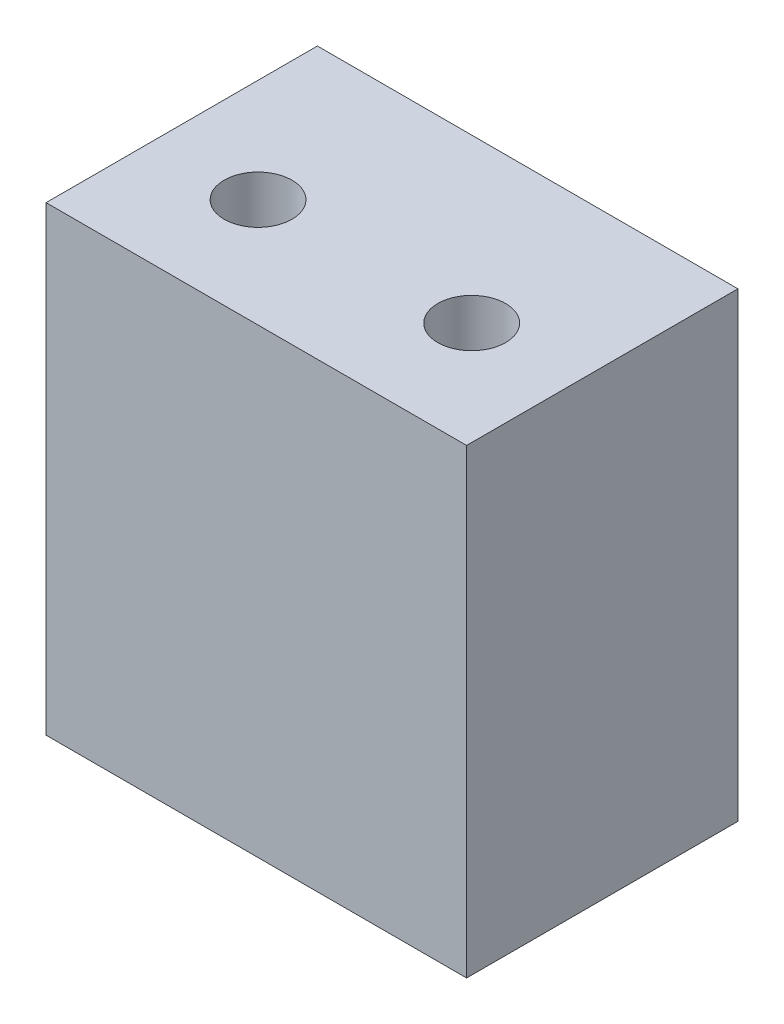
from build123d import *

# Parameters (mm, degrees)
SKETCH1_W           = 19.685
SKETCH1_H           = 21.59
BOSS_EXTRUDE1_DEPTH = 12.7
SKETCH7_R           = 1.5875
CUT_EXTRUDE1_DEPTH  = 6.35


with BuildPart() as part:
    # Sketch1 → Boss-Extrude1 (new body)
    with BuildSketch(Plane.XY):
        Rectangle(SKETCH1_W, SKETCH1_H)
    extrude(amount=BOSS_EXTRUDE1_DEPTH)

    # Sketch7 → Cut-Extrude1 (cut)
    with BuildSketch(Plane(origin=(0, 10.795, 0), x_dir=(1, 0, 0), z_dir=(0, 1, 0))):
        with Locations((5, -7.62)):
            Circle(SKETCH7_R)
        with Locations((-5, -7.62)):
            Circle(SKETCH7_R)
    extrude(amount=-CUT_EXTRUDE1_DEPTH, mode=Mode.SUBTRACT)


solid = part.part
